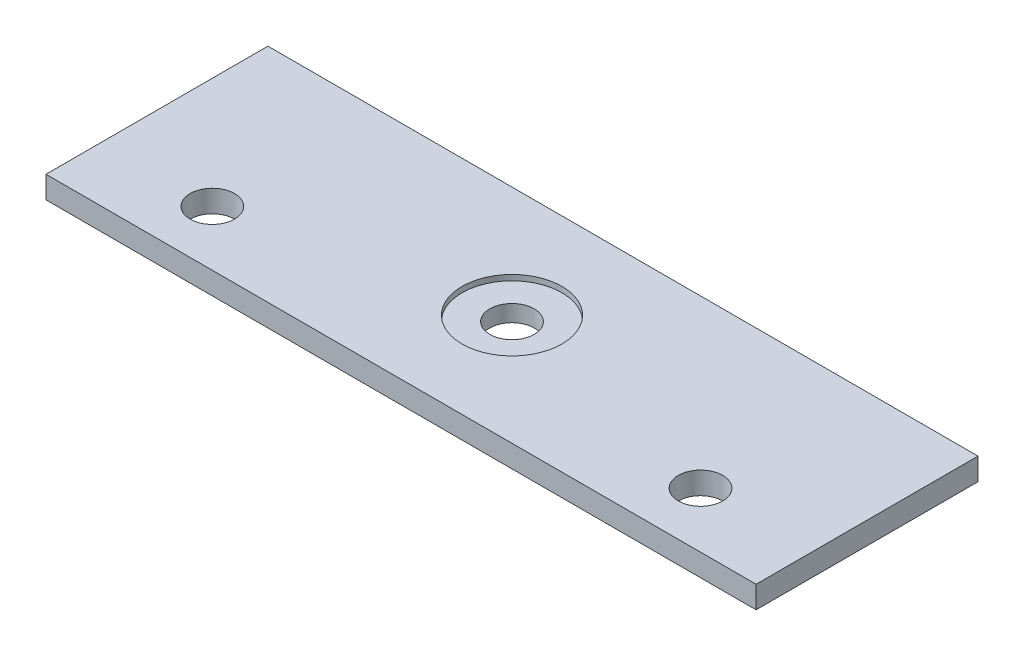
from build123d import *

# Parameters (mm, degrees)
SKETCH8_W           = 203.2
SKETCH8_H           = 63.5
BOSS_EXTRUDE1_DEPTH = 6.35
SKETCH9_R           = 14.2875
CUT_EXTRUDE2_DEPTH  = 1.5875
SKETCH10_R          = 6.35
CUT_EXTRUDE3_DEPTH  = 5.7625
SKETCH11_R          = 6.35
CUT_EXTRUDE4_DEPTH  = 7.35


with BuildPart() as part:
    # Sketch8 → Boss-Extrude1 (new body)
    with BuildSketch(Plane(origin=(0, 0, 0), x_dir=(1, 0, 0), z_dir=(0, 1, 0))):
        with Locations((-101.6, 31.75)):
            Rectangle(SKETCH8_W, SKETCH8_H)
    extrude(amount=BOSS_EXTRUDE1_DEPTH)

    # Sketch9 → Cut-Extrude2 (cut)
    with BuildSketch(Plane(origin=(0, 6.35, 0), x_dir=(1, 0, 0), z_dir=(0, 1, 0))):
        with Locations((-101.6, 31.75)):
            Circle(SKETCH9_R)
    extrude(amount=-CUT_EXTRUDE2_DEPTH, mode=Mode.SUBTRACT)

    # Sketch10 → Cut-Extrude3 (cut, through all)
    with BuildSketch(Plane(origin=(0, 4.7625, 0), x_dir=(1, 0, 0), z_dir=(0, 1, 0))):
        with Locations((-101.6, 31.75)):
            Circle(SKETCH10_R)
    extrude(amount=-CUT_EXTRUDE3_DEPTH, mode=Mode.SUBTRACT)

    # Sketch11 → Cut-Extrude4 (cut, through all)
    with BuildSketch(Plane(origin=(0, 6.35, 0), x_dir=(1, 0, 0), z_dir=(0, 1, 0))):
        with Locations((-171.45, 15.85)):
            Circle(SKETCH11_R)
        with Locations((-31.75, 15.85)):
            Circle(SKETCH11_R)
    extrude(amount=-CUT_EXTRUDE4_DEPTH, mode=Mode.SUBTRACT)


solid = part.part
